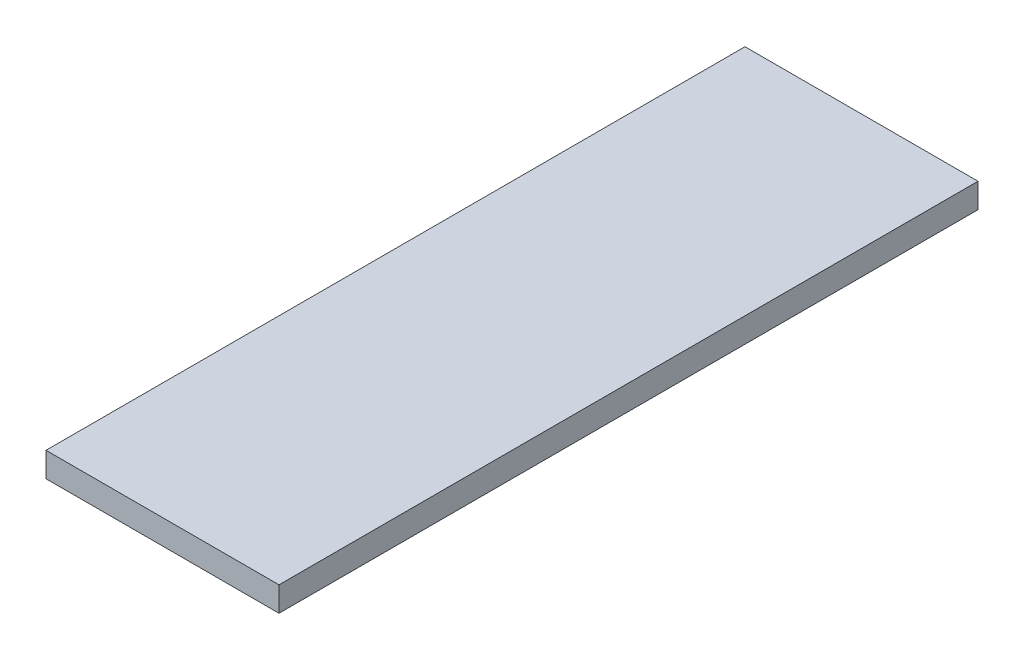
from build123d import *

# Parameters (mm, degrees)
SKETCH1_W           = 30
SKETCH1_H           = 90
BOSS_EXTRUDE1_DEPTH = 3.175


with BuildPart() as part:
    # Sketch1 → Boss-Extrude1 (new body)
    with BuildSketch(Plane(origin=(0, 0, 0), x_dir=(1, 0, 0), z_dir=(0, 1, 0))):
        with Locations((15, 45)):
            Rectangle(SKETCH1_W, SKETCH1_H)
    extrude(amount=BOSS_EXTRUDE1_DEPTH)


solid = part.part
